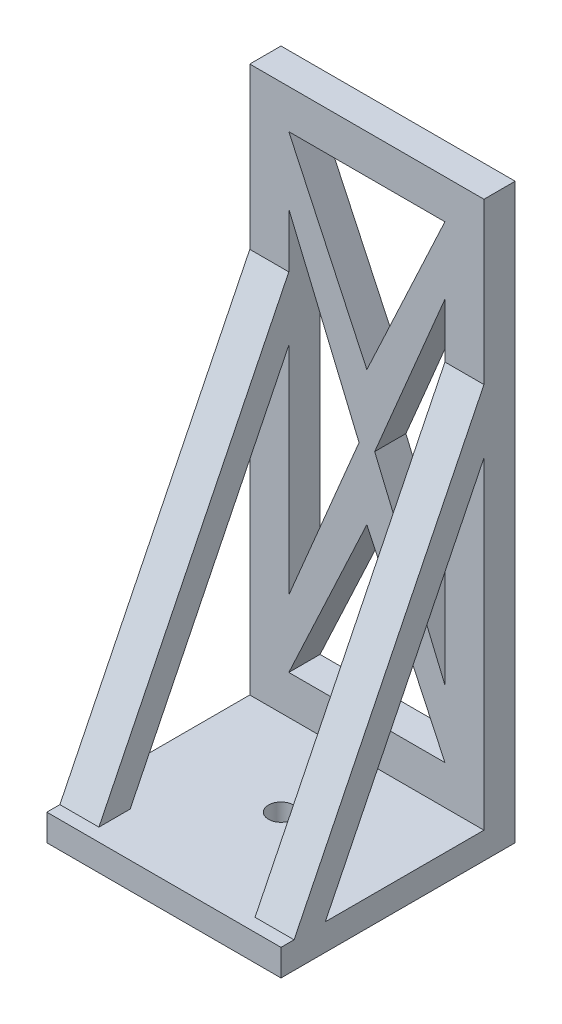
from build123d import *

# Parameters (mm, degrees)
SKETCH1_W           = 30
SKETCH1_H           = 30
SKETCH1_R           = 1.6
BOSS_EXTRUDE1_DEPTH = 3.4
SKETCH2_W           = 30
SKETCH2_H           = 4
BOSS_EXTRUDE2_DEPTH = 70
CUT_EXTRUDE2_REACH  = 6
BOSS_EXTRUDE3_DEPTH = 5
BOSS_EXTRUDE4_DEPTH = 5


with BuildPart() as part:
    # Sketch1 → Boss-Extrude1 (new body)
    with BuildSketch(Plane(origin=(0, 0, 0), x_dir=(1, 0, 0), z_dir=(0, 1, 0))):
        Rectangle(SKETCH1_W, SKETCH1_H)
        Circle(SKETCH1_R, mode=Mode.SUBTRACT)
    extrude(amount=BOSS_EXTRUDE1_DEPTH)

    # Sketch2 → Boss-Extrude2 (add)
    with BuildSketch(Plane(origin=(0, 3.4, 0), x_dir=(1, 0, 0), z_dir=(0, 1, 0))):
        with Locations((0, 13)):
            Rectangle(SKETCH2_W, SKETCH2_H)
    extrude(amount=BOSS_EXTRUDE2_DEPTH)

    # Sketch3 → Cut-Extrude2 (cut, up to next)
    with BuildSketch(Plane.XY.offset(-11), mode=Mode.PRIVATE) as cut_extrude2_sk1:
        Polygon((1, 38.4), (10, 16.994902993), (10, 59.805097007), align=None)
    cut_extrude2_tool1 = extrude(cut_extrude2_sk1.sketch, amount=-CUT_EXTRUDE2_REACH, mode=Mode.PRIVATE) & part.part
    add(cut_extrude2_tool1.solids().sort_by_distance((7, 38.4, -11))[0], mode=Mode.SUBTRACT)
    # Sketch3 → Cut-Extrude2 (cut, up to next)
    with BuildSketch(Plane.XY.offset(-11), mode=Mode.PRIVATE) as cut_extrude2_sk2:
        Polygon((-1, 38.4), (-10, 59.805097007), (-10, 16.994902993), align=None)
    cut_extrude2_tool2 = extrude(cut_extrude2_sk2.sketch, amount=-CUT_EXTRUDE2_REACH, mode=Mode.PRIVATE) & part.part
    add(cut_extrude2_tool2.solids().sort_by_distance((-7, 38.4, -11))[0], mode=Mode.SUBTRACT)
    # Sketch3 → Cut-Extrude2 (cut, up to next)
    with BuildSketch(Plane.XY.offset(-11), mode=Mode.PRIVATE) as cut_extrude2_sk3:
        Polygon((-10, 68.4), (0, 46.994902993), (10, 68.4), align=None)
    cut_extrude2_tool3 = extrude(cut_extrude2_sk3.sketch, amount=-CUT_EXTRUDE2_REACH, mode=Mode.PRIVATE) & part.part
    add(cut_extrude2_tool3.solids().sort_by_distance((0, 61.264968, -11))[0], mode=Mode.SUBTRACT)
    # Sketch3 → Cut-Extrude2 (cut, up to next)
    with BuildSketch(Plane.XY.offset(-11), mode=Mode.PRIVATE) as cut_extrude2_sk4:
        Polygon((0, 29.805097007), (-10, 8.4), (10, 8.4), align=None)
    cut_extrude2_tool4 = extrude(cut_extrude2_sk4.sketch, amount=-CUT_EXTRUDE2_REACH, mode=Mode.PRIVATE) & part.part
    add(cut_extrude2_tool4.solids().sort_by_distance((0, 15.535032, -11))[0], mode=Mode.SUBTRACT)

    # Sketch4 → Boss-Extrude3 (add)
    with BuildSketch(Plane.ZY.offset(15)):
        Polygon((-15, 52.839280477), (-11, 52.839280477), (15, 0), (11, 0), align=None)
    extrude(amount=-BOSS_EXTRUDE3_DEPTH)

    # Sketch5 → Boss-Extrude4 (add)
    with BuildSketch(Plane(origin=(15, 0, 0), x_dir=(0, 0, -1), z_dir=(1, 0, 0))):
        Polygon((15, 52.839280477), (11, 52.839280477), (-15, 0), (-11, 0), align=None)
    extrude(amount=-BOSS_EXTRUDE4_DEPTH)


solid = part.part
